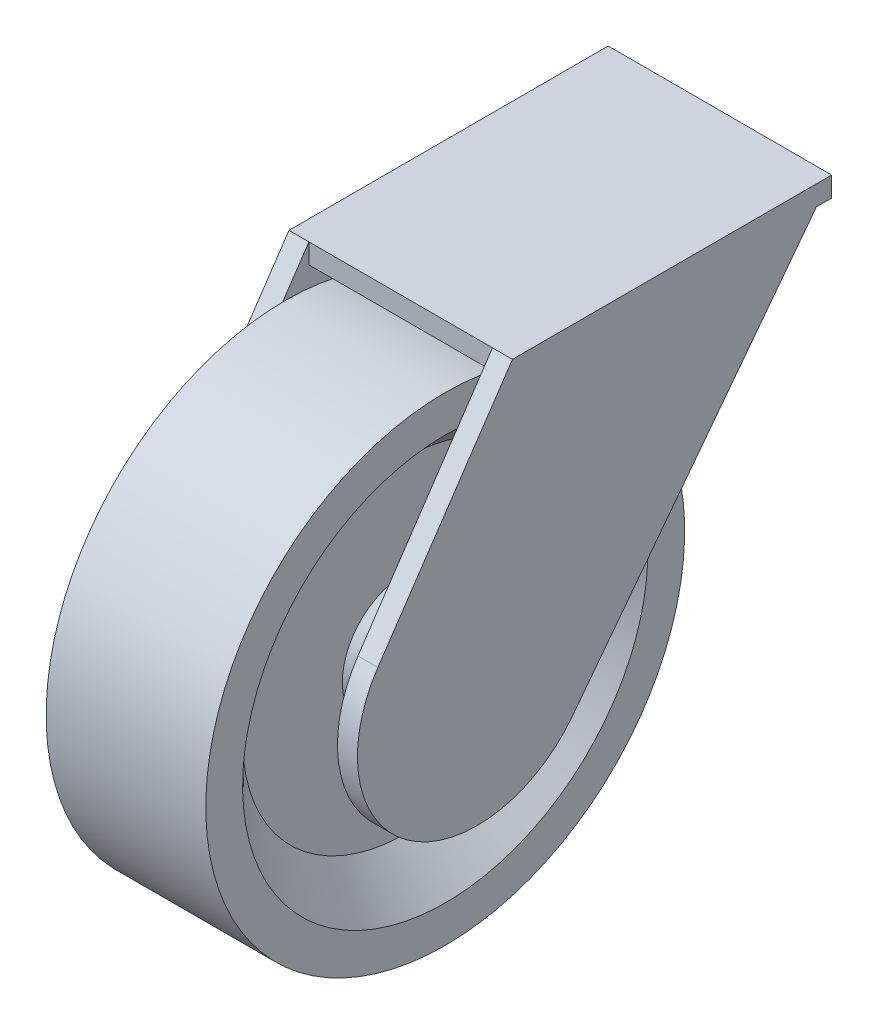
from build123d import *

# Parameters (mm, degrees)
SKETCH3_R           = 7.5
BOSS_EXTRUDE1_DEPTH = 8
BOSS_EXTRUDE2_DEPTH = 5
SKETCH5_W           = 56
SKETCH5_H           = 80
BOSS_EXTRUDE3_DEPTH = 5


with BuildPart() as part:
    # Sketch1 → Revolve1 (revolve)
    with BuildSketch(Plane.XY):
        Polygon((-40, 60), (0, 60), (0, 50.773502692), (-10, 40.773502692), (-10, 15.773502692), (0, 10), (0, 0), (-40, 0), (-40, 10), (-30, 15.773502692), (-30, 40.773502692), (-40, 50.773502692), align=None)
    revolve(axis=Axis((0, 0, 0), (-1, 0, 0)))

    # Sketch3 → Boss-Extrude1 (add)
    with BuildSketch(Plane(origin=(0, 0, 0), x_dir=(0, 0, -1), z_dir=(1, 0, 0))):
        Circle(SKETCH3_R)
    boss_extrude1 = extrude(amount=BOSS_EXTRUDE1_DEPTH)

    # Sketch4 → Boss-Extrude2 (add)
    with BuildSketch(Plane(origin=(8, 0, 0), x_dir=(0, 0, -1), z_dir=(1, 0, 0))):
        with BuildLine():
            Line((8.84577787, 66.773419664), (88.84577787, 66.773419664))
            Line((88.84577787, 66.773419664), (23.828381591, -18.226580336))
            ThreePointArc((23.828381591, -18.226580336), (-17.50778863, -24.361390299), (-24.872723871, 16.773419664))
            Line((-24.872723871, 16.773419664), (8.84577787, 66.773419664))
        make_face()
    boss_extrude2 = extrude(amount=-BOSS_EXTRUDE2_DEPTH)

    # Mirror1: Boss-Extrude1, Boss-Extrude2 across plane
    add(boss_extrude1.mirror(Plane(origin=(-20, 0, 0), x_dir=(0, 0, 1), z_dir=(1, 0, 0))))
    add(boss_extrude2.mirror(Plane(origin=(-20, 0, 0), x_dir=(0, 0, 1), z_dir=(1, 0, 0))))

    # Sketch5 → Boss-Extrude3 (add)
    with BuildSketch(Plane(origin=(0, 66.773419664, 0), x_dir=(1, 0, 0), z_dir=(0, 1, 0))):
        with Locations((-20, 48.84577787)):
            Rectangle(SKETCH5_W, SKETCH5_H)
    extrude(amount=-BOSS_EXTRUDE3_DEPTH)


solid = part.part
